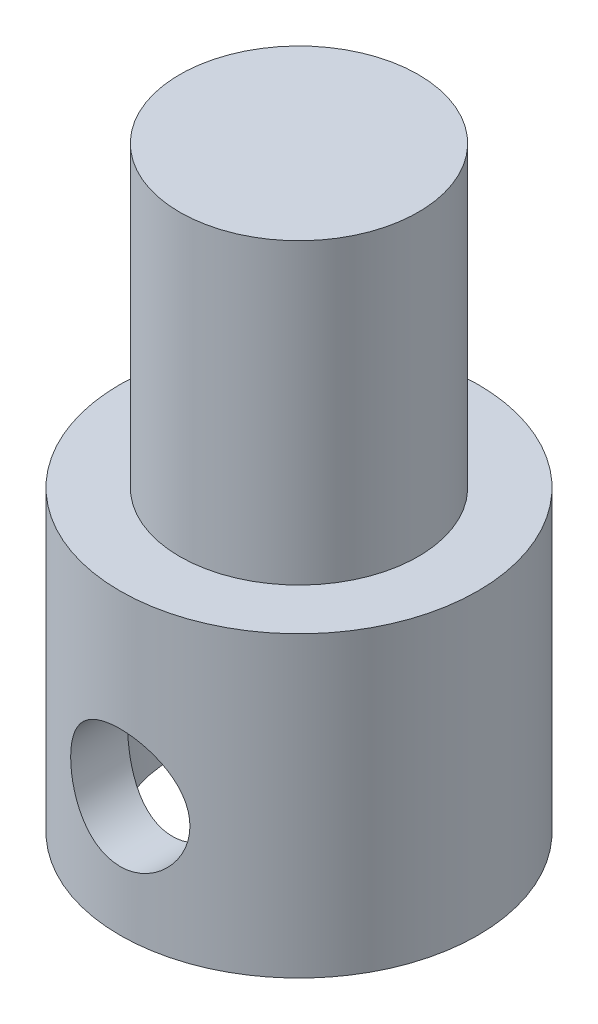
from build123d import *

# Parameters (mm, degrees)
CROQUIS1_R                 = 6
SALIENTE_EXTRUIR1_DEPTH    = 10
CROQUIS2_R                 = 4
SALIENTE_EXTRUIR2_DEPTH    = 10
CROQUIS3_R                 = 4.25
CORTAR_EXTRUIR1_DEPTH      = 8
CROQUIS4_R                 = 2
CORTAR_EXTRUIR2_DEPTH      = 7
CORTAR_EXTRUIR2_DEPTH_BACK = 7


with BuildPart() as part:
    # Croquis1 → Saliente-Extruir1 (new body)
    with BuildSketch(Plane(origin=(0, 0, 0), x_dir=(1, 0, 0), z_dir=(0, 1, 0))):
        Circle(CROQUIS1_R)
    extrude(amount=SALIENTE_EXTRUIR1_DEPTH)

    # Croquis2 → Saliente-Extruir2 (add)
    with BuildSketch(Plane(origin=(0, 10, 0), x_dir=(1, 0, 0), z_dir=(0, 1, 0))):
        Circle(CROQUIS2_R)
    extrude(amount=SALIENTE_EXTRUIR2_DEPTH)

    # Croquis3 → Cortar-Extruir1 (cut)
    with BuildSketch(Plane.XZ):
        Circle(CROQUIS3_R)
    extrude(amount=-CORTAR_EXTRUIR1_DEPTH, mode=Mode.SUBTRACT)

    # Croquis4 → Cortar-Extruir2 (cut, two sides)
    with BuildSketch(Plane.XY) as cortar_extruir2_sk:
        with Locations((0, 4)):
            Circle(CROQUIS4_R)
    extrude(amount=CORTAR_EXTRUIR2_DEPTH, mode=Mode.SUBTRACT)
    extrude(cortar_extruir2_sk.sketch, amount=-CORTAR_EXTRUIR2_DEPTH_BACK, mode=Mode.SUBTRACT)


solid = part.part
